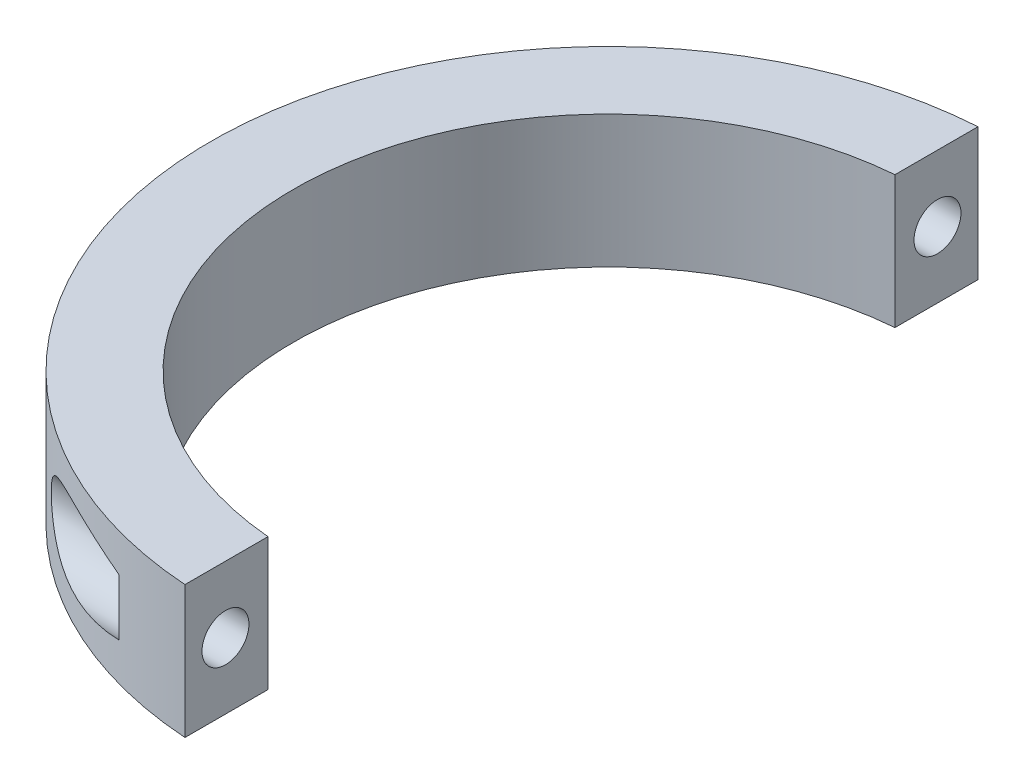
from build123d import *

# Parameters (mm, degrees)
BOSS_EXTRUDE1_DEPTH = 12.7
SKETCH2_R           = 2.25
CUT_EXTRUDE1_DEPTH  = 39.1
CUT_EXTRUDE2_START  = -10.16
SKETCH3_R           = 3.75
CUT_EXTRUDE2_DEPTH  = 28.9400001
SKETCH4_W           = 2.54
SKETCH4_H           = 76.2
CUT_EXTRUDE3_DEPTH  = 13.7000001


with BuildPart() as part:
    # Sketch1 → Boss-Extrude1 (new body)
    with BuildSketch(Plane(origin=(0, 0, 0), x_dir=(1, 0, 0), z_dir=(0, 1, 0))):
        with BuildLine():
            Line((0, 30.1625), (0, 38.1))
            ThreePointArc((0, 38.1), (-38.1, 0), (0, -38.1))
            Line((0, -38.1), (0, -30.1625))
            ThreePointArc((0, -30.1625), (-30.1625, 0), (0, 30.1625))
        make_face()
    extrude(amount=BOSS_EXTRUDE1_DEPTH)

    # Sketch2 → Cut-Extrude1 (cut, through all)
    with BuildSketch(Plane(origin=(0, 0, 0), x_dir=(0, 0, -1), z_dir=(1, 0, 0))):
        with Locations((-34.13125, 6.35)):
            Circle(SKETCH2_R)
        with Locations((34.13125, 6.35)):
            Circle(SKETCH2_R)
    extrude(amount=-CUT_EXTRUDE1_DEPTH, mode=Mode.SUBTRACT)

    # Sketch3 → Cut-Extrude2 (cut, through all)
    with BuildSketch(Plane(origin=(0, 0, 0), x_dir=(0, 0, -1), z_dir=(1, 0, 0)).offset(CUT_EXTRUDE2_START)):
        with Locations((34.13125, 6.35)):
            Circle(SKETCH3_R)
        with Locations((-34.13125, 6.35)):
            Circle(SKETCH3_R)
    extrude(amount=-CUT_EXTRUDE2_DEPTH, mode=Mode.SUBTRACT)

    # Sketch4 → Cut-Extrude3 (cut, through all)
    with BuildSketch(Plane(origin=(0, 12.7, 0), x_dir=(1, 0, 0), z_dir=(0, 1, 0))):
        with Locations((-1.27, 0)):
            Rectangle(SKETCH4_W, SKETCH4_H)
    extrude(amount=-CUT_EXTRUDE3_DEPTH, mode=Mode.SUBTRACT)


solid = part.part
